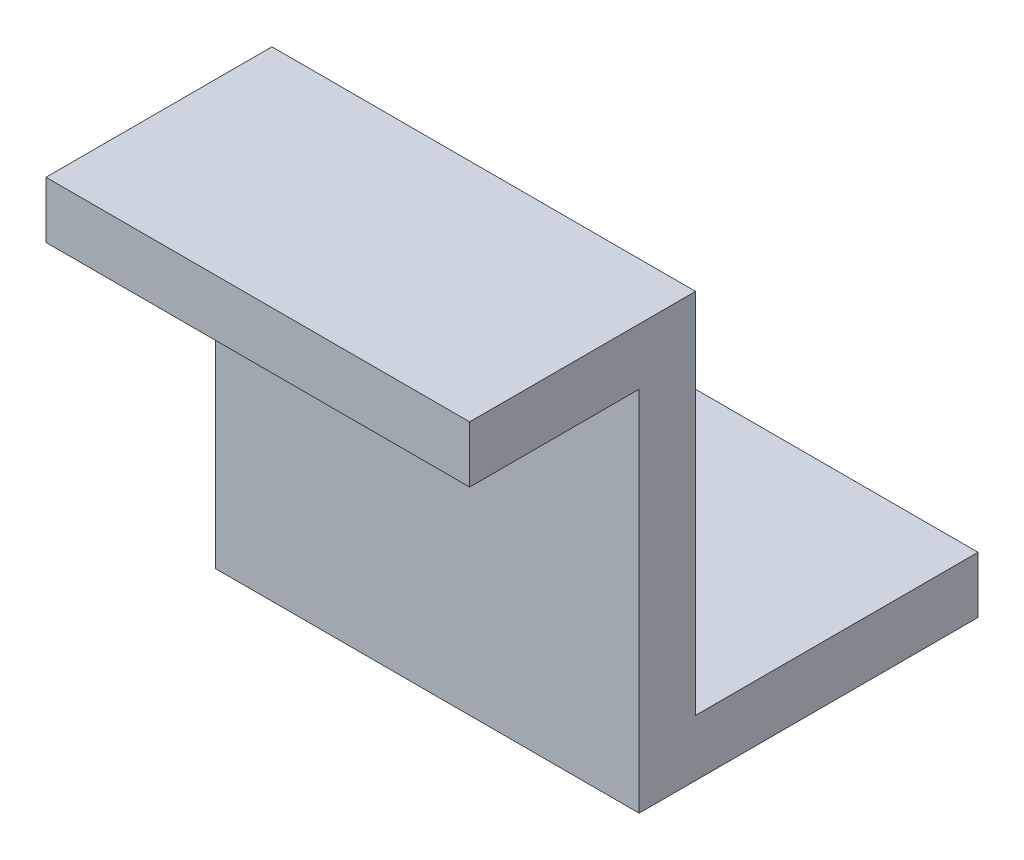
from build123d import *

# Parameters (mm, degrees)
BOSS_EXTRUDE1_DEPTH = 15
CUT_EXTRUDE1_REACH  = 4
SKETCH3_R           = 1.5


with BuildPart() as part:
    # Sketch1 → Boss-Extrude1 (new body)
    with BuildSketch(Plane(origin=(0, 0, 0), x_dir=(0, 0, -1), z_dir=(1, 0, 0))):
        Polygon((0, 0), (8, 0), (8, -13), (18, -13), (18, -15), (6, -15), (6, -2), (0, -2), align=None)
    extrude(amount=-BOSS_EXTRUDE1_DEPTH)

    # Sketch3 → Cut-Extrude1 (cut, up to next)
    with BuildSketch(Plane(origin=(0, -13, 0), x_dir=(1, 0, 0), z_dir=(0, 1, 0)), mode=Mode.PRIVATE) as cut_extrude1_sk1:
        with Locations((-7.5, 13)):
            Circle(SKETCH3_R)
    cut_extrude1_tool1 = extrude(cut_extrude1_sk1.sketch, amount=-CUT_EXTRUDE1_REACH, mode=Mode.PRIVATE) & part.part
    add(cut_extrude1_tool1.solids().sort_by_distance((-7.5, -13, -13))[0], mode=Mode.SUBTRACT)


solid = part.part
